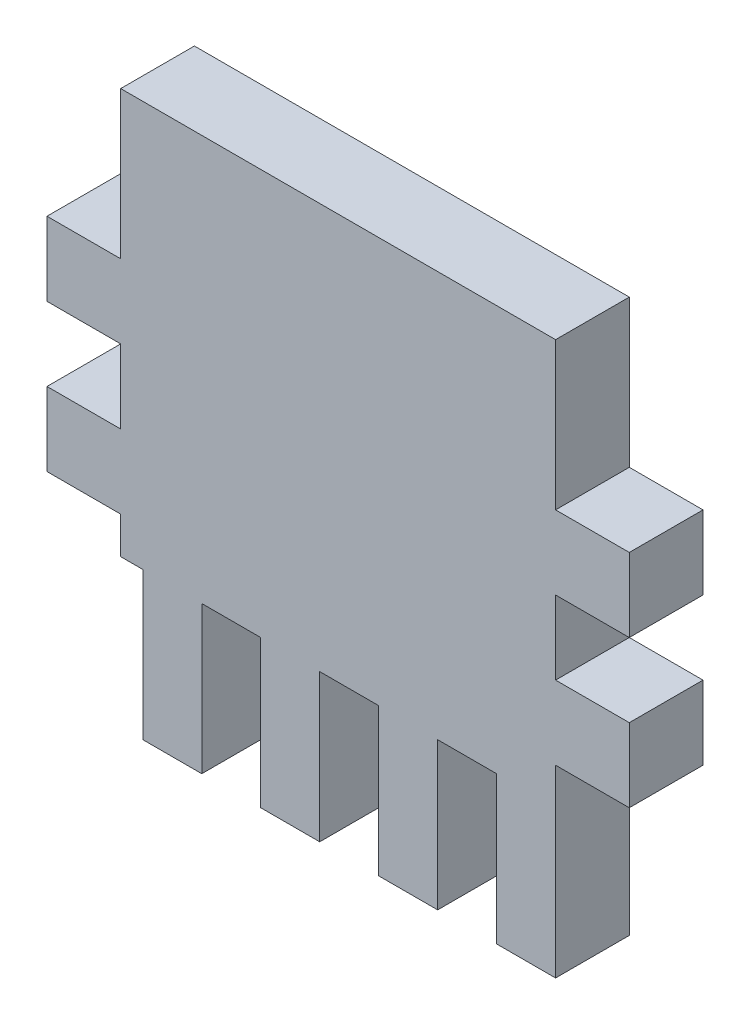
from build123d import *

# Parameters (mm, degrees)
BOSS_EXTRU_1_DEPTH = 5


with BuildPart() as part:
    # Esquisse2 → Boss.-Extru.1 (new body)
    with BuildSketch(Plane.XY):
        Polygon((-13.909341466, -8.713061229), (-12.409341466, -8.713061229), (-12.409341466, -18.713061229), (-8.409341466, -18.713061229), (-8.409341466, -8.713061229), (-4.409341466, -8.713061229), (-4.409341466, -18.713061229), (-0.409341466, -18.713061229), (-0.409341466, -8.713061229), (3.590658534, -8.713061229), (3.590658534, -18.713061229), (7.590658534, -18.713061229), (7.590658534, -8.713061229), (11.590658534, -8.713061229), (11.590658534, -18.713061229), (15.590658534, -18.713061229), (15.590658534, -6.213061229), (20.590658534, -6.213061229), (20.590658534, -1.213061229), (15.590658534, -1.213061229), (15.590658534, 3.786938771), (20.590658534, 3.786938771), (20.590658534, 8.786938771), (15.590658534, 8.786938771), (15.590658534, 18.786938771), (-13.909341466, 18.786938771), (-13.909341466, 8.786938771), (-18.909341466, 8.786938771), (-18.909341466, 3.786938771), (-13.909341466, 3.786938771), (-13.909341466, -1.213061229), (-18.909341466, -1.213061229), (-18.909341466, -6.213061229), (-13.909341466, -6.213061229), align=None)
    extrude(amount=BOSS_EXTRU_1_DEPTH)


solid = part.part
